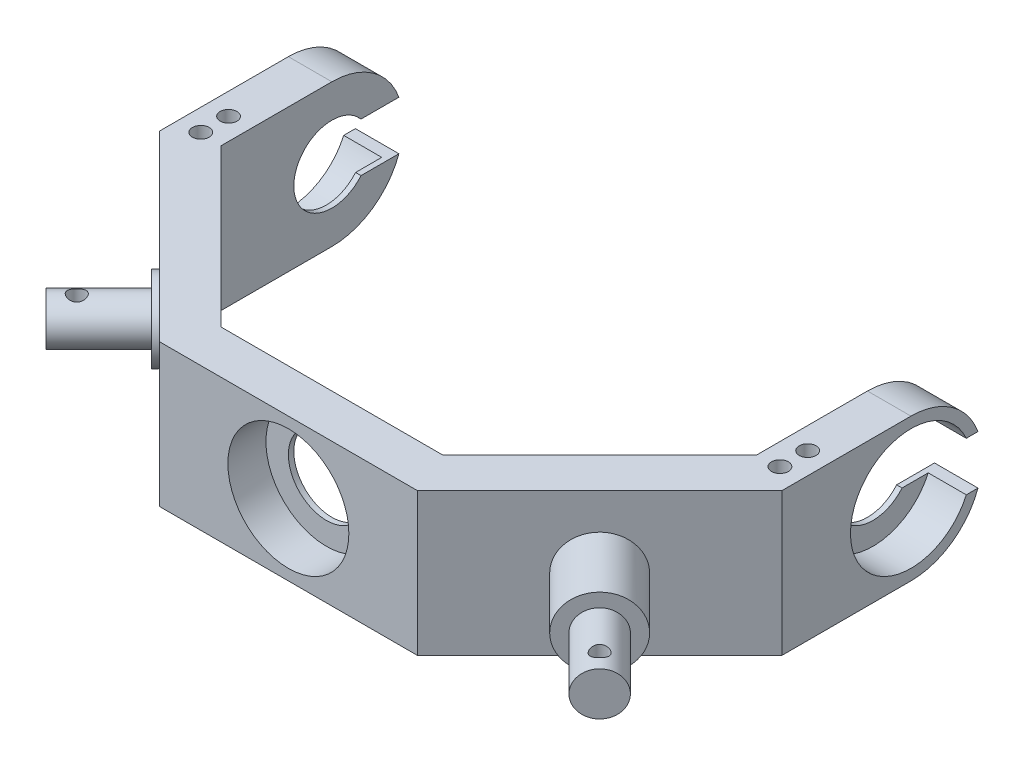
from build123d import *

# Parameters (mm, degrees)
BOSS_EXTRUDE1_DEPTH = 13.125
SKETCH2_R           = 7
CUT_EXTRUDE1_DEPTH  = 106.5
SKETCH2_4_R         = 11.125
SKETCH2_4_R_2       = 7
CUT_EXTRUDE2_DEPTH  = 7
SKETCH4_R           = 4
BOSS_EXTRUDE3_DEPTH = 10
SKETCH5_R           = 6.5
BOSS_EXTRUDE4_DEPTH = 1
CIRPATTERN1_COUNT   = 2
CIRPATTERN1_ANGLE   = 45
SKETCH9_R           = 4
BOSS_EXTRUDE6_DEPTH = 20
CUT_EXTRUDE6_REACH  = 96.758
SKETCH10_R          = 1.5
SKETCH11_R          = 6.5
BOSS_EXTRUDE7_DEPTH = 13.5
SKETCH12_R          = 4
BOSS_EXTRUDE8_DEPTH = 13.75
SKETCH13_R          = 1.5
CUT_EXTRUDE7_DEPTH  = 13.75
SKETCH14_R          = 11.125
CUT_EXTRUDE8_DEPTH  = 17
SKETCH15_R          = 7
CUT_EXTRUDE9_DEPTH  = 1
SKETCH16_R          = 1.55
CUT_EXTRUDE10_DEPTH = 93.310955607


with BuildPart() as part:
    # Sketch1 → Boss-Extrude1 (new, symmetric)
    with BuildSketch(Plane(origin=(0, 0, 0), x_dir=(1, 0, 0), z_dir=(0, 1, 0))):
        Polygon((-49.25, 13.125), (-49.25, -13.125), (-49.25, -20.400017947), (-20.400017947, -49.25), (20.400017947, -49.25), (49.25, -20.400017947), (49.25, -13.125), (49.25, 13.125), (57.25, 13.125), (57.25, -23.713726446), (23.713726446, -57.25), (-23.713726446, -57.25), (-57.25, -23.713726446), (-57.25, 13.125), align=None)
    extrude(amount=BOSS_EXTRUDE1_DEPTH, both=True)

    # Sketch2 → Cut-Extrude1 (cut)
    with BuildSketch(Plane.ZY.offset(57.25)):
        with BuildLine():
            Line((-13.125, 13.125), (-13.125, 0))
            ThreePointArc((-13.125, 0), (-12.924585281, 2.284889562), (-12.329461667, 4.5))
            ThreePointArc((-12.329461667, 4.5), (-7.523400993, 10.7547228), (0, 13.125))
            Line((0, 13.125), (-13.125, 13.125))
        make_face()
        with BuildLine():
            ThreePointArc((-12.329461667, -4.5), (-12.924585281, -2.284889562), (-13.125, 0))
            Line((-13.125, 0), (-13.125, -13.125))
            Line((-13.125, -13.125), (0, -13.125))
            ThreePointArc((0, -13.125), (-7.523400993, -10.7547228), (-12.329461667, -4.5))
        make_face()
        Circle(SKETCH2_R)
        with BuildLine():
            ThreePointArc((-5.361902647, -4.5), (-6.577739678, -2.394439545), (-7, 0))
            Line((-7, 0), (-11.125, 0))
            ThreePointArc((-11.125, 0), (-10.88472093, -2.299668513), (-10.174262873, -4.5))
            Line((-10.174262873, -4.5), (-5.361902647, -4.5))
        make_face()
        with BuildLine():
            Line((-11.125, 0), (-7, 0))
            ThreePointArc((-7, 0), (-6.577739678, 2.394439545), (-5.361902647, 4.5))
            Line((-5.361902647, 4.5), (-10.174262873, 4.5))
            ThreePointArc((-10.174262873, 4.5), (-10.88472093, 2.299668513), (-11.125, 0))
        make_face()
        with BuildLine():
            ThreePointArc((-10.174262873, -4.5), (-10.88472093, -2.299668513), (-11.125, 0))
            Line((-11.125, 0), (-13.125, 0))
            ThreePointArc((-13.125, 0), (-12.924585281, -2.284889562), (-12.329461667, -4.5))
            Line((-12.329461667, -4.5), (-10.174262873, -4.5))
        make_face()
        with BuildLine():
            Line((-13.125, 0), (-11.125, 0))
            ThreePointArc((-11.125, 0), (-10.88472093, 2.299668513), (-10.174262873, 4.5))
            Line((-10.174262873, 4.5), (-12.329461667, 4.5))
            ThreePointArc((-12.329461667, 4.5), (-12.924585281, 2.284889562), (-13.125, 0))
        make_face()
    cut_extrude1 = extrude(amount=-CUT_EXTRUDE1_DEPTH, mode=Mode.SUBTRACT)

    # Sketch2_4 → Cut-Extrude2 (cut)
    with BuildSketch(Plane.ZY.offset(57.25)):
        Circle(SKETCH2_4_R)
        Circle(SKETCH2_4_R_2, mode=Mode.SUBTRACT)
    cut_extrude2 = extrude(amount=-CUT_EXTRUDE2_DEPTH, mode=Mode.SUBTRACT)

    # Mirror1: Cut-Extrude1, Cut-Extrude2 across plane
    add(cut_extrude1.mirror(Plane(origin=(0, 0, 0), x_dir=(0, 0, 1), z_dir=(1, 0, 0))), mode=Mode.SUBTRACT)
    add(cut_extrude2.mirror(Plane(origin=(0, 0, 0), x_dir=(0, 0, 1), z_dir=(1, 0, 0))), mode=Mode.SUBTRACT)

    # Sketch4 → Boss-Extrude3 (add)
    with BuildSketch(Plane(origin=(-40.481863223, 0, 40.481863223), x_dir=(0.7071067811865489, 0, 0.7071067811865461), z_dir=(-0.7071067811865461, 0, 0.7071067811865489))):
        with Locations(Location((0, 0, 0), (0, 0, 180))):
            Circle(SKETCH4_R)
    boss_extrude3 = extrude(amount=BOSS_EXTRUDE3_DEPTH)

    # Sketch5 → Boss-Extrude4 (add)
    with BuildSketch(Plane(origin=(-40.481863223, 0, 40.481863223), x_dir=(0.7071067811865489, 0, 0.7071067811865461), z_dir=(-0.7071067811865461, 0, 0.7071067811865489))):
        with Locations(Location((0, 0, 0), (0, 0, 180))):
            Circle(SKETCH5_R)
    boss_extrude4 = extrude(amount=BOSS_EXTRUDE4_DEPTH)

    # CirPattern1: Boss-Extrude3, Boss-Extrude4 ×2 about axis
    cirpattern1_axis = Axis((0, 14.4375, 0), (0, 1, 0))
    add([boss_extrude3.rotate(cirpattern1_axis, i * CIRPATTERN1_ANGLE / (CIRPATTERN1_COUNT - 1)) for i in range(1, CIRPATTERN1_COUNT)])
    add([boss_extrude4.rotate(cirpattern1_axis, i * CIRPATTERN1_ANGLE / (CIRPATTERN1_COUNT - 1)) for i in range(1, CIRPATTERN1_COUNT)])

    # Sketch9 → Boss-Extrude6 (add)
    with BuildSketch(Plane(origin=(-47.552931035, 0, 47.552931035), x_dir=(0.7071067811865489, 0, 0.7071067811865461), z_dir=(-0.7071067811865461, 0, 0.7071067811865489))):
        Circle(SKETCH9_R)
    extrude(amount=BOSS_EXTRUDE6_DEPTH)

    # Sketch10 → Cut-Extrude6 (cut, up to next)
    with BuildSketch(Plane(origin=(0, 4, 0), x_dir=(1, 0, 0), z_dir=(0, 1, 0)), mode=Mode.PRIVATE) as cut_extrude6_sk1:
        Polygon((-48.083261121, -53.74011537), (-53.74011537, -48.083261121), (-64.523493783, -58.866639534), (-58.866639534, -64.523493783), align=None)
    cut_extrude6_tool1 = extrude(cut_extrude6_sk1.sketch, amount=-CUT_EXTRUDE6_REACH, mode=Mode.PRIVATE) & part.part
    # Sketch10 → Cut-Extrude6 (cut, up to next)
    with BuildSketch(Plane(origin=(0, 4, 0), x_dir=(1, 0, 0), z_dir=(0, 1, 0)), mode=Mode.PRIVATE) as cut_extrude6_sk2:
        with Locations(Location((-48.083261121, -48.083261121, 0), (0, 0, 270))):
            Circle(SKETCH10_R)
    cut_extrude6_tool2 = extrude(cut_extrude6_sk2.sketch, amount=-CUT_EXTRUDE6_REACH, mode=Mode.PRIVATE) & part.part
    add(cut_extrude6_tool1.solids().sort_by_distance((-56.303377, 4, 56.303377))[0], mode=Mode.SUBTRACT)
    add(cut_extrude6_tool2.solids().sort_by_distance((-48.083261, 4, 48.083261))[0], mode=Mode.SUBTRACT)

    # Sketch11 → Boss-Extrude7 (add)
    with BuildSketch(Plane(origin=(40.481863223, 0, 40.481863223), x_dir=(0.7071067811865442, 0, -0.7071067811865508), z_dir=(0.7071067811865508, 0, 0.7071067811865442))):
        with Locations(Location((0, 0, 0), (0, 0, 180))):
            Circle(SKETCH11_R)
    extrude(amount=BOSS_EXTRUDE7_DEPTH)

    # Sketch12 → Boss-Extrude8 (add)
    with BuildSketch(Plane(origin=(50.027804769, 0, 50.027804769), x_dir=(0.7071067811865442, 0, -0.7071067811865508), z_dir=(0.7071067811865508, 0, 0.7071067811865442))):
        Circle(SKETCH12_R)
    extrude(amount=BOSS_EXTRUDE8_DEPTH)

    # Sketch13 → Cut-Extrude7 (cut)
    with BuildSketch(Plane(origin=(0, 4, 0), x_dir=(1, 0, 0), z_dir=(0, 1, 0))):
        with Locations(Location((56.922095886, -56.922095886, 0), (0, 0, 270))):
            Circle(SKETCH13_R)
    extrude(amount=-CUT_EXTRUDE7_DEPTH, mode=Mode.SUBTRACT)

    # Sketch14 → Cut-Extrude8 (cut)
    with BuildSketch(Plane.XY.offset(67.25)):
        Circle(SKETCH14_R)
    extrude(amount=-CUT_EXTRUDE8_DEPTH, mode=Mode.SUBTRACT)

    # Sketch15 → Cut-Extrude9 (cut)
    with BuildSketch(Plane.XY.offset(50.25)):
        Circle(SKETCH15_R)
    extrude(amount=-CUT_EXTRUDE9_DEPTH, mode=Mode.SUBTRACT)

    # Sketch16 → Cut-Extrude10 (cut, through all)
    with BuildSketch(Plane(origin=(0, 13.125, 0), x_dir=(1, 0, 0), z_dir=(0, 1, 0))):
        with Locations(Location((-53.25, -15, 0), (0, 0, 270))):
            Circle(SKETCH16_R)
        with Locations(Location((-53.25, -20.1, 0), (0, 0, 270))):
            Circle(SKETCH16_R)
    cut_extrude10 = extrude(amount=-CUT_EXTRUDE10_DEPTH, mode=Mode.SUBTRACT)

    # Mirror3: Cut-Extrude10 across plane
    add(cut_extrude10.mirror(Plane(origin=(0, 0, 0), x_dir=(0, 0, 1), z_dir=(1, 0, 0))), mode=Mode.SUBTRACT)


solid = part.part
